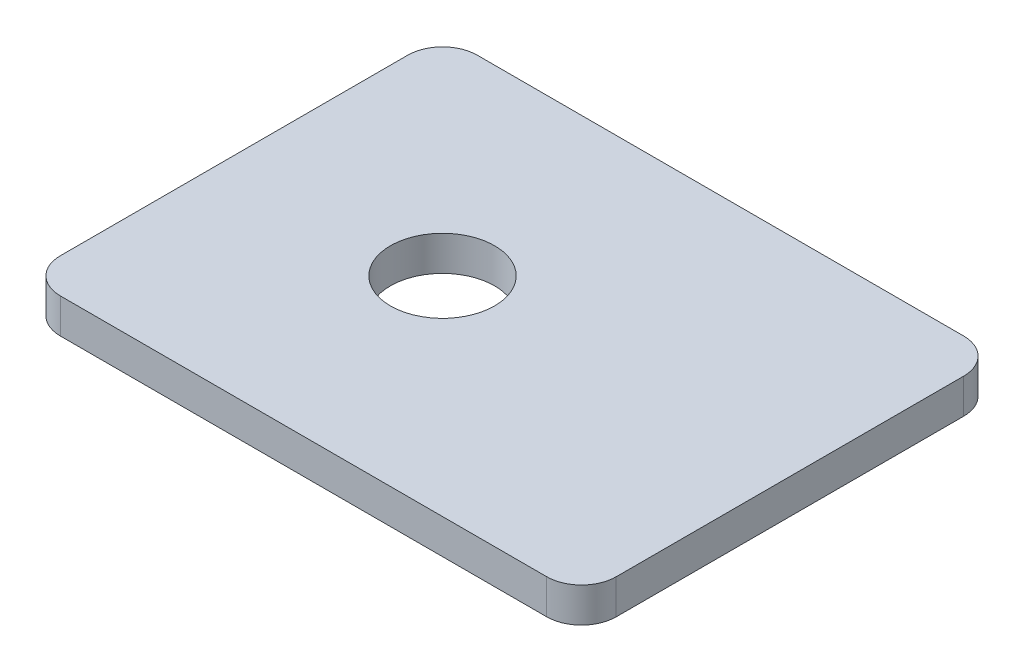
from build123d import *

# Parameters (mm, degrees)
BOSS_EXTRUDE1_DEPTH          = 3.175
F_3_8_0_375_DIAMETER_HOLE1_D = 9.525


with BuildPart() as part:
    # Sketch1 → Boss-Extrude1 (new body)
    with BuildSketch(Plane(origin=(0, 0, 0), x_dir=(1, 0, 0), z_dir=(0, 1, 0))):
        with BuildLine():
            Line((3.175, 0), (47.625, 0))
            ThreePointArc((47.625, 0), (49.87006403, 0.92993597), (50.8, 3.175))
            Line((50.8, 3.175), (50.8, 34.925))
            ThreePointArc((50.8, 34.925), (49.87006403, 37.17006403), (47.625, 38.1))
            Line((47.625, 38.1), (3.175, 38.1))
            ThreePointArc((3.175, 38.1), (0.92993597, 37.17006403), (0, 34.925))
            Line((0, 34.925), (0, 3.175))
            ThreePointArc((0, 3.175), (0.92993597, 0.92993597), (3.175, 0))
        make_face()
    extrude(amount=BOSS_EXTRUDE1_DEPTH)

    # 3/8 (0.375) Diameter Hole1 (through all)
    with Locations(Plane(origin=(0, 3.175, 0), x_dir=(1, 0, 0), z_dir=(0, 1, 0))):
        with Locations((19.05, 19.05)):
            Hole(F_3_8_0_375_DIAMETER_HOLE1_D / 2)


solid = part.part
